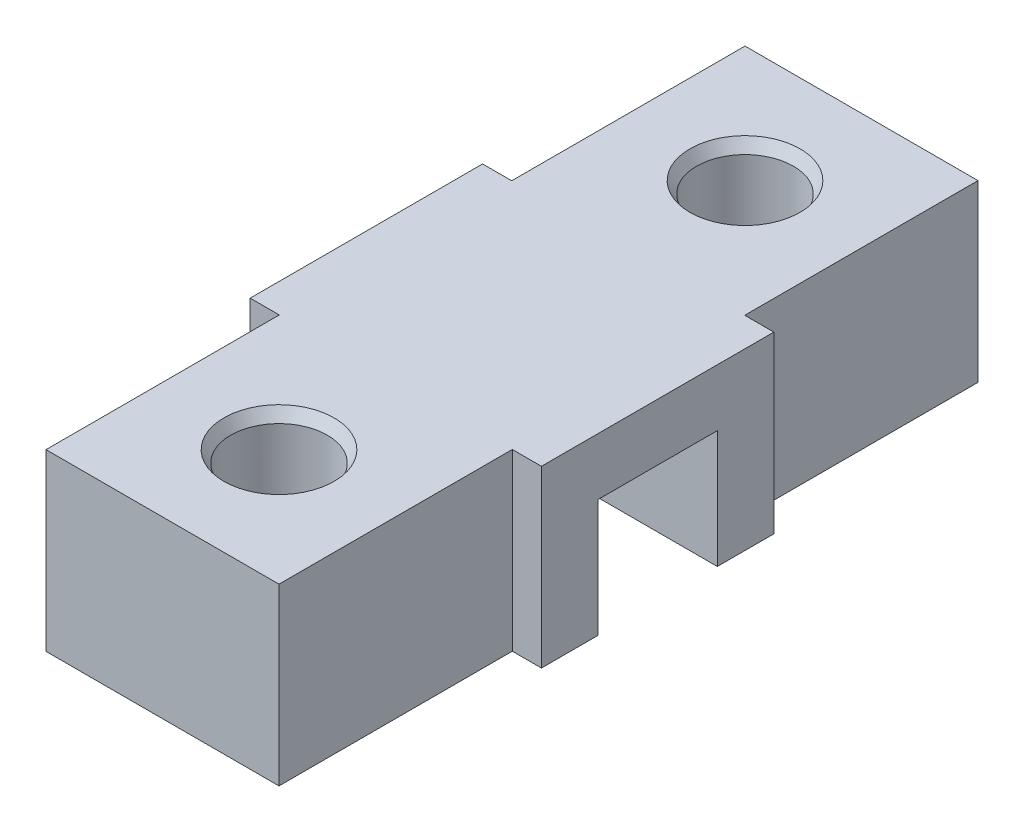
from build123d import *

# Parameters (mm, degrees)
SKETCH1_W                = 20
SKETCH1_H                = 60
BOSS_EXTRUDE1_DEPTH      = 15
SKETCH2_W                = 10.25
SKETCH2_H                = 10.1
CUT_EXTRUDE1_DEPTH       = 1
CUT_EXTRUDE1_DEPTH_BACK  = 21
SKETCH3_R                = 4.15
CUT_EXTRUDE2_DEPTH       = 16
BOSS_EXTRUDE2_DEPTH      = 2.5
BOSS_EXTRUDE2_DEPTH_BACK = 22.5
CHAMFER1_SIZE            = 1
CHAMFER1_SIZE2           = 0.577350269
CHAMFER1_PART_2_SIZE     = 1
CHAMFER1_PART_2_SIZE2    = 0.577350269


with BuildPart() as part:
    # Sketch1 → Boss-Extrude1 (new body)
    with BuildSketch(Plane(origin=(0, 0, 0), x_dir=(1, 0, 0), z_dir=(0, 1, 0))):
        Rectangle(SKETCH1_W, SKETCH1_H)
    extrude(amount=BOSS_EXTRUDE1_DEPTH)

    # Sketch2 → Cut-Extrude1 (cut, two sides)
    with BuildSketch(Plane(origin=(10, 0, 0), x_dir=(0, 0, -1), z_dir=(1, 0, 0))) as cut_extrude1_sk:
        with Locations((0, 5.05)):
            Rectangle(SKETCH2_W, SKETCH2_H)
    extrude(amount=CUT_EXTRUDE1_DEPTH, mode=Mode.SUBTRACT)
    extrude(cut_extrude1_sk.sketch, amount=-CUT_EXTRUDE1_DEPTH_BACK, mode=Mode.SUBTRACT)

    # Sketch3 → Cut-Extrude2 (cut, through all)
    with BuildSketch(Plane.XZ):
        with Locations(Location((0, 20, 0), (0, 0, 270))):  # turned: the seam where the file's is
            Circle(SKETCH3_R)
        with Locations(Location((0, -20, 0), (0, 0, 270))):  # turned: the seam where the file's is
            Circle(SKETCH3_R)
    extrude(amount=-CUT_EXTRUDE2_DEPTH, mode=Mode.SUBTRACT)

    # Sketch4 → Boss-Extrude2 (add, two sides)
    with BuildSketch(Plane(origin=(10, 0, 0), x_dir=(0, 0, -1), z_dir=(1, 0, 0))) as boss_extrude2_sk:
        Polygon((-5.125, 0), (-9.975, 0), (-9.975, 15), (9.975, 15), (9.975, 0), (5.125, 0), (5.125, 10.1), (-5.125, 10.1), align=None)
    extrude(amount=BOSS_EXTRUDE2_DEPTH)
    extrude(boss_extrude2_sk.sketch, amount=-BOSS_EXTRUDE2_DEPTH_BACK)

    # Chamfer1
    chamfer1_edges = [part.edges().sort_by_distance(p)[0] for p in [
        (0, 15, 24.15),
    ]]
    chamfer1_side = [part.faces().sort_by_distance(p)[0] for p in [
        (0, 7.5, 24.15),
    ]]
    chamfer(chamfer1_edges, length=CHAMFER1_SIZE, length2=CHAMFER1_SIZE2, reference=chamfer1_side[0])

    # Chamfer1 part 2
    chamfer1_part_2_edges = [part.edges().sort_by_distance(p)[0] for p in [
        (0, 15, -15.85),
    ]]
    chamfer1_part_2_side = [part.faces().sort_by_distance(p)[0] for p in [
        (0, 7.5, -15.85),
    ]]
    chamfer(chamfer1_part_2_edges, length=CHAMFER1_PART_2_SIZE, length2=CHAMFER1_PART_2_SIZE2, reference=chamfer1_part_2_side[0])


solid = part.part
